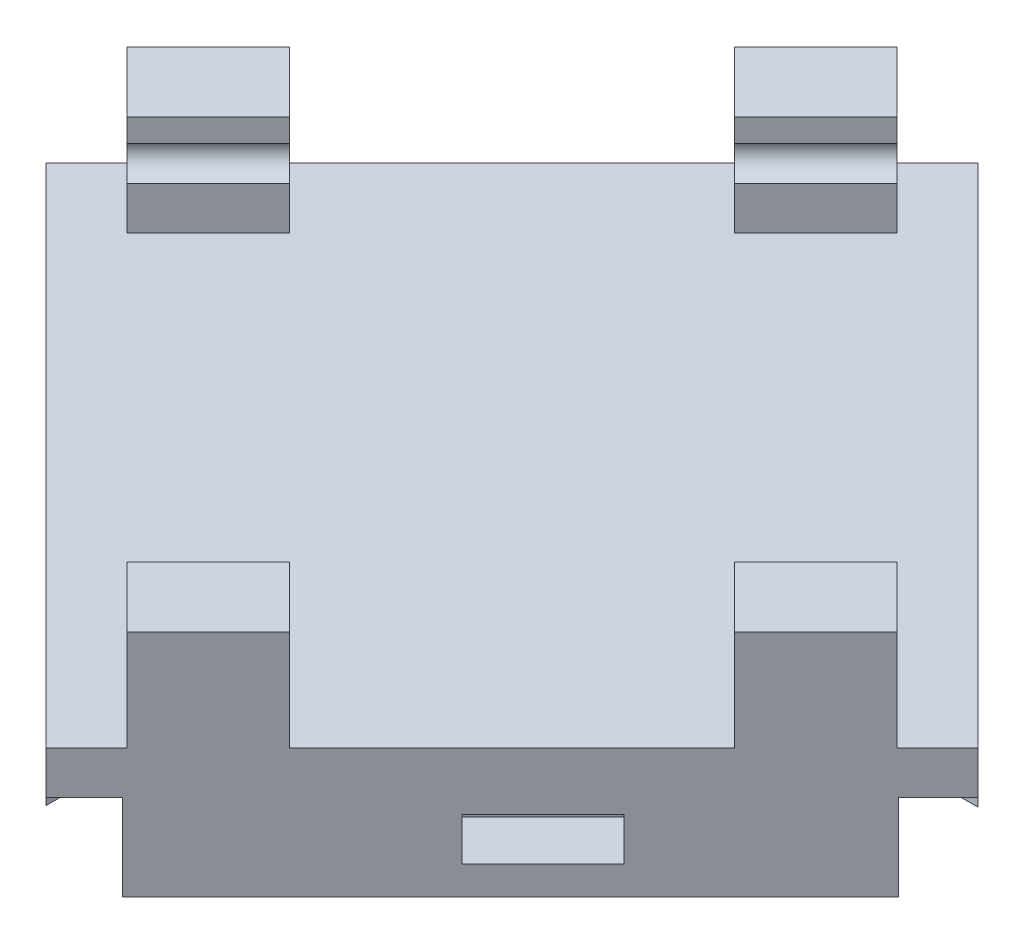
from build123d import *

# Parameters (mm, degrees)
BOSS_EXTRUDE2_DEPTH     = 4.5
CUT_EXTRUDE1_DEPTH      = 3
BOSS_EXTRUDE3_DEPTH     = 3.5
CUT_EXTRUDE2_DEPTH      = 15.5
CUT_EXTRUDE2_DEPTH_BACK = 34.485281374
CUT_EXTRUDE5_DEPTH      = 34.485281374
SKETCH10_W              = 4
SKETCH10_H              = 1.5
CUT_EXTRUDE6_DEPTH      = 2
SKETCH11_W              = 4
SKETCH11_H              = 1.5
CUT_EXTRUDE7_DEPTH      = 2
SKETCH12_W              = 4
SKETCH12_H              = 1.5
CUT_EXTRUDE8_DEPTH      = 2
SKETCH13_W              = 4
SKETCH13_H              = 1.5
CUT_EXTRUDE9_DEPTH      = 2


with BuildPart() as part:
    # Sketch2 → Boss-Extrude2 (new body)
    with BuildSketch(Plane(origin=(0, 0, 0), x_dir=(1, 0, 0), z_dir=(0, 1, 0))):
        Polygon((-4.567545122, 15.820593449), (13.110124407, -1.85707608), (-3.14292392, -18.110124407), (-20.820593449, -0.432454878), align=None)
    extrude(amount=BOSS_EXTRUDE2_DEPTH)

    # Sketch4 → Cut-Extrude1 (cut)
    with BuildSketch(Plane(origin=(0, 0, 0), x_dir=(1, 0, 0), z_dir=(0, 1, 0))):
        Polygon((-18.008282848, -3.244765479), (-5.905234521, -3.244765479), (-5.905234521, -15.347813806), (-3.14292392, -18.110124407), (-1.805234521, -16.772435009), (-1.805234521, -3.244765479), (11.722435009, -3.244765479), (13.110124407, -1.85707608), (10.397813806, 0.855234521), (-1.832165216, 0.855234521), (-1.99606638, 13.249114707), (-4.567545122, 15.820593449), (-5.905234521, 14.482904051), (-5.905234521, 0.855234521), (-19.532904051, 0.855234521), (-20.820593449, -0.432454878), align=None)
    extrude(amount=CUT_EXTRUDE1_DEPTH, mode=Mode.SUBTRACT)

    # Sketch5 → Boss-Extrude3 (add)
    with BuildSketch(Plane(origin=(0, 4.5, 0), x_dir=(1, 0, 0), z_dir=(0, 1, 0))):
        Polygon((8.86748372, -6.099716767), (11.695910845, -3.271289643), (9.574590502, -1.149969299), (6.746163377, -3.978396424), align=None)
        Polygon((-6.688865466, 9.456632419), (-3.860438341, 12.285059543), (-5.981758685, 14.406379887), (-8.810185809, 11.577952762), align=None)
        Polygon((-17.285059543, -1.139561659), (-14.456632419, 1.688865466), (-16.577952762, 3.810185809), (-19.406379887, 0.981758685), align=None)
        Polygon((-1.728710357, -16.695910845), (1.099716767, -13.86748372), (-1.021603576, -11.746163377), (-3.850030701, -14.574590502), align=None)
    extrude(amount=BOSS_EXTRUDE3_DEPTH)

    # Sketch6 → Cut-Extrude2 (cut, two sides)
    with BuildSketch(Plane(origin=(4.212310601, 0, -4.212310601), x_dir=(-0.707106781, 0, -0.707106781), z_dir=(0.707106781, 0, -0.707106781))) as cut_extrude2_sk:
        with BuildLine():
            Line((-7.58340896, 6), (-7.58340896, 7.2))
            ThreePointArc((-7.58340896, 7.2), (-8.18340896, 6.6), (-7.58340896, 6))
        make_face()
    extrude(amount=CUT_EXTRUDE2_DEPTH, mode=Mode.SUBTRACT)
    extrude(cut_extrude2_sk.sketch, amount=-CUT_EXTRUDE2_DEPTH_BACK, mode=Mode.SUBTRACT)

    # Sketch7 → Cut-Extrude5 (cut, through all)
    with BuildSketch(Plane(origin=(4.212310601, 0, -4.212310601), x_dir=(-0.707106781, 0, -0.707106781), z_dir=(0.707106781, 0, -0.707106781))):
        with BuildLine():
            Line((11.41659104, 7.2), (11.41659104, 6))
            ThreePointArc((11.41659104, 6), (12.01659104, 6.6), (11.41659104, 7.2))
        make_face()
    extrude(amount=-CUT_EXTRUDE5_DEPTH, mode=Mode.SUBTRACT)

    # Sketch10 → Cut-Extrude6 (cut)
    with BuildSketch(Plane(origin=(5.626524164, 0, -5.626524164), x_dir=(-0.707106781, 0, -0.707106781), z_dir=(0.707106781, 0, -0.707106781))):
        with Locations((2.014970927, 1.75)):
            Rectangle(SKETCH10_W, SKETCH10_H)
    extrude(amount=-CUT_EXTRUDE6_DEPTH, mode=Mode.SUBTRACT)

    # Sketch11 → Cut-Extrude7 (cut)
    with BuildSketch(Plane(origin=(-10.626524164, 0, 10.626524164), x_dir=(0.707106781, 0, 0.707106781), z_dir=(-0.707106781, 0, 0.707106781))):
        with Locations((-2.088088155, 1.75)):
            Rectangle(SKETCH11_W, SKETCH11_H)
    extrude(amount=-CUT_EXTRUDE7_DEPTH, mode=Mode.SUBTRACT)

    # Sketch12 → Cut-Extrude8 (cut)
    with BuildSketch(Plane(origin=(7.483600244, 0, 7.483600244), x_dir=(0.707106781, 0, -0.707106781), z_dir=(0.707106781, 0, 0.707106781))):
        with Locations((-2.770382387, 1.75)):
            Rectangle(SKETCH12_W, SKETCH12_H)
    extrude(amount=-CUT_EXTRUDE8_DEPTH, mode=Mode.SUBTRACT)

    # Sketch13 → Cut-Extrude9 (cut)
    with BuildSketch(Plane(origin=(-10.194069286, 0, -10.194069286), x_dir=(-0.707106781, 0, 0.707106781), z_dir=(-0.707106781, 0, -0.707106781))):
        with Locations((4.442106781, 1.75)):
            Rectangle(SKETCH13_W, SKETCH13_H)
    extrude(amount=-CUT_EXTRUDE9_DEPTH, mode=Mode.SUBTRACT)


solid = part.part
